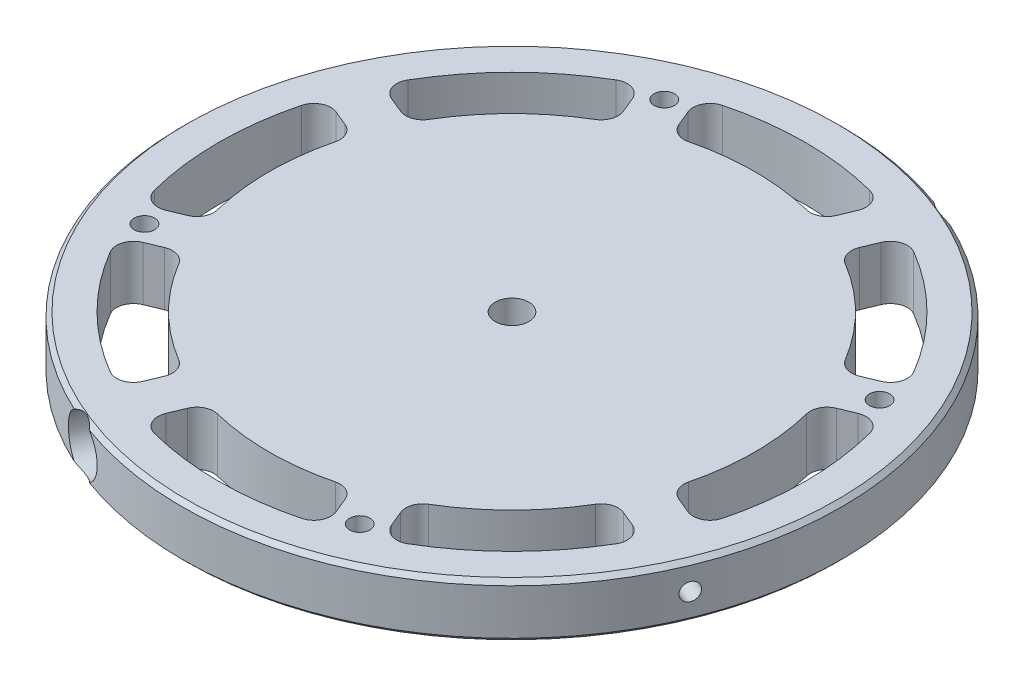
from build123d import *

# Parameters (mm, degrees)
SKETCH2_W                   = 77.55
SKETCH2_H                   = 12.7
F_12_0_189_DIAMETER_HOLE1_D = 4.8006
CIRPATTERN3_COUNT           = 4
CUT_EXTRUDE1_DEPTH          = 13.7
FILLET1_R                   = 4
CIRPATTERN4_COUNT           = 8
FILLET1_OF_CIRPATTERN4_R    = 4
CHAMFER1_SIZE               = 1
SKETCH15_W                  = 2.0447
SKETCH15_H                  = 101.323957926
SKETCH19_R                  = 6.25
CUT_EXTRUDE3_DEPTH          = 5
CIRPATTERN5_COUNT           = 2
CIRPATTERN6_COUNT           = 2
SKETCH22_R                  = 3.96875
CUT_EXTRUDE4_DEPTH          = 12.8


with BuildPart() as part:
    # Sketch2 → Revolve1 (revolve)
    with BuildSketch(Plane(origin=(0, 0, 0), x_dir=(0, 0, -1), z_dir=(1, 0, 0))):
        with Locations((-38.775, 6.35)):
            Rectangle(SKETCH2_W, SKETCH2_H)
    revolve(axis=Axis((0, -0.888756804, 0), (0, 1, 0)))

    # #12 (0.189) Diameter Hole1 (through all)
    with Locations(Plane(origin=(0, 12.7, 0), x_dir=(1, 0, 0), z_dir=(0, 1, 0))):
        with Locations((-25.333643223, 61.160825052)):
            f_12_0_189_diameter_hole1 = Hole(F_12_0_189_DIAMETER_HOLE1_D / 2)

    # CirPattern3: #12 (0.189) Diameter Hole1 ×4 about axis
    cirpattern3_axis = Axis((0, 0, 0), (0, 1, 0))
    for i in range(1, CIRPATTERN3_COUNT):
        add(f_12_0_189_diameter_hole1.rotate(cirpattern3_axis, i * 360 / CIRPATTERN3_COUNT), mode=Mode.SUBTRACT)

    # Sketch8 → Cut-Extrude1 (cut, through all)
    with BuildSketch(Plane(origin=(0, 12.7, 0), x_dir=(1, 0, 0), z_dir=(0, 1, 0))):
        with BuildLine():
            Line((-17.167098173, 54.510670885), (-21.735525784, 65.539830782))
            ThreePointArc((-21.735525784, 65.539830782), (0, 69.05), (21.735525784, 65.539830782))
            Line((21.735525784, 65.539830782), (17.167098173, 54.510670885))
            ThreePointArc((17.167098173, 54.510670885), (0, 57.15), (-17.167098173, 54.510670885))
        make_face()
    cut_extrude1 = extrude(amount=-CUT_EXTRUDE1_DEPTH, mode=Mode.SUBTRACT)

    # Fillet1
    fillet1_edges = [part.edges().sort_by_distance(p)[0] for p in [
        (17.167098173, 6.35, -54.510670885),
        (-17.167098173, 6.35, -54.510670885),
        (-21.735525784, 6.35, -65.539830782),
        (21.735525784, 6.35, -65.539830782),
    ]]
    fillet(fillet1_edges, radius=FILLET1_R)

    # CirPattern4: Cut-Extrude1 ×8 about axis
    cirpattern4_axis = Axis((0, 0, 0), (0, 1, 0))
    for i in range(1, CIRPATTERN4_COUNT):
        add(cut_extrude1.rotate(cirpattern4_axis, i * 360 / CIRPATTERN4_COUNT), mode=Mode.SUBTRACT)

    # Fillet1 of CirPattern4
    fillet1_of_cirpattern4_edges = [part.edges().sort_by_distance(p)[0] for p in [
        (-26.405893498, 6.35, -50.683836561),
        (-50.683836561, 6.35, -26.405893498),
        (-61.712996458, 6.35, -30.974321109),
        (-30.974321109, 6.35, -61.712996458),
        (-54.510670885, 6.35, -17.167098173),
        (-54.510670885, 6.35, 17.167098173),
        (-65.539830782, 6.35, 21.735525784),
        (-65.539830782, 6.35, -21.735525784),
        (-50.683836561, 6.35, 26.405893498),
        (-26.405893498, 6.35, 50.683836561),
        (-30.974321109, 6.35, 61.712996458),
        (-61.712996458, 6.35, 30.974321109),
        (-17.167098173, 6.35, 54.510670885),
        (17.167098173, 6.35, 54.510670885),
        (21.735525784, 6.35, 65.539830782),
        (-21.735525784, 6.35, 65.539830782),
        (26.405893498, 6.35, 50.683836561),
        (50.683836561, 6.35, 26.405893498),
        (61.712996458, 6.35, 30.974321109),
        (30.974321109, 6.35, 61.712996458),
        (54.510670885, 6.35, 17.167098173),
        (54.510670885, 6.35, -17.167098173),
        (65.539830782, 6.35, -21.735525784),
        (65.539830782, 6.35, 21.735525784),
        (50.683836561, 6.35, -26.405893498),
        (26.405893498, 6.35, -50.683836561),
        (30.974321109, 6.35, -61.712996458),
        (61.712996458, 6.35, -30.974321109),
    ]]
    fillet(fillet1_of_cirpattern4_edges, radius=FILLET1_OF_CIRPATTERN4_R)

    # Chamfer1
    chamfer1_edges = [part.edges().sort_by_distance(p)[0] for p in [
        (0, 12.7, -77.55),
        (0, 0, -77.55),
    ]]
    chamfer(chamfer1_edges, length=CHAMFER1_SIZE)

    # Sketch15 → #20 (0.161) Diameter Hole1 (revolve, cut)
    with BuildSketch(Plane(origin=(0, 6.35, 0), x_dir=(-0.382683432, 0, 0.923879533), z_dir=(0, 1, 0))):
        with Locations((1.02235, 50.661978963)):
            Rectangle(SKETCH15_W, SKETCH15_H)
    revolve(axis=Axis((-5.866635031, 6.35, -2.430039796), (0.923879533, 0, 0.382683432)), mode=Mode.SUBTRACT)

    # Sketch19 → Cut-Extrude3 (cut)
    with BuildSketch(Plane(origin=(29.67710018, 0, -71.646857746), x_dir=(-0.923879533, 0, -0.382683432), z_dir=(0.382683432, 0, -0.923879533))):
        with Locations((0, 6.35)):
            Circle(SKETCH19_R)
    cut_extrude3 = extrude(amount=-CUT_EXTRUDE3_DEPTH, mode=Mode.SUBTRACT)

    # CirPattern5: Cut-Extrude3 ×2 about axis
    cirpattern5_axis = Axis((0, -0.888756804, 0), (0, 1, 0))
    for i in range(1, CIRPATTERN5_COUNT):
        add(cut_extrude3.rotate(cirpattern5_axis, i * 360 / CIRPATTERN5_COUNT), mode=Mode.SUBTRACT)

    # Sketch21 → #10-24 Tapped Hole1 (revolve, cut)
    with BuildSketch(Plane(origin=(-27.763683018, 6.35, 67.027460084), x_dir=(0.923879533, 0, 0.382683432), z_dir=(0, 1, 0))):
        Polygon((0, 0), (0, 51.940824014), (1.89865, 50.8), (1.89865, 0), align=None)
    f_10_24_tapped_hole1 = revolve(axis=Axis((-30.193722814, 6.35, 72.894095115), (0.382683432, 0, -0.923879533)), mode=Mode.SUBTRACT)

    # CirPattern6: #10-24 Tapped Hole1 ×2 about axis
    cirpattern6_axis = Axis((0, -0.888756804, 0), (0, 1, 0))
    for i in range(1, CIRPATTERN6_COUNT):
        add(f_10_24_tapped_hole1.rotate(cirpattern6_axis, i * 360 / CIRPATTERN6_COUNT), mode=Mode.SUBTRACT)

    # Sketch22 → Cut-Extrude4 (cut)
    with BuildSketch(Plane(origin=(0, 12.7, 0), x_dir=(1, 0, 0), z_dir=(0, 1, 0))):
        Circle(SKETCH22_R)
    extrude(amount=-CUT_EXTRUDE4_DEPTH, mode=Mode.SUBTRACT)


solid = part.part
